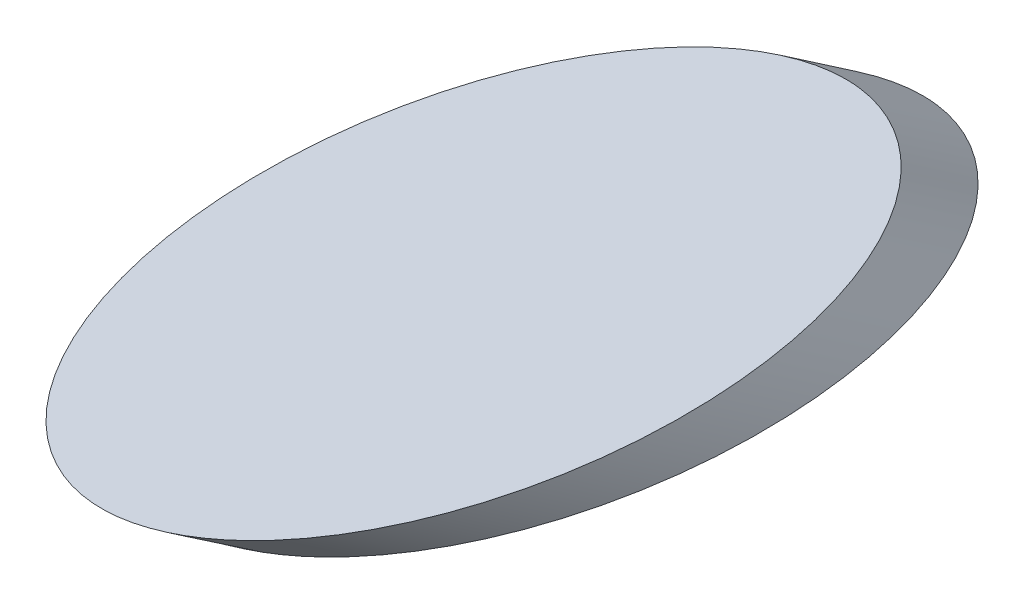
from build123d import *

# Parameters (mm, degrees)
SKETCH_1_RX = 14.115
SKETCH_1_RY = 8


with BuildPart() as part:
    # 扫描1: sweep along a path in 草图2
    with BuildLine(Plane(origin=(0, 0, 0), x_dir=(0, 0, -1), z_dir=(1, 0, 0))) as sweep_1_path:
        Line((-14.115, 0), (-11.19771593, -2))
    # 草图1 → 扫描1 (sweep)
    with BuildSketch(Plane(origin=(0, 0, 0), x_dir=(1, 0, 0), z_dir=(0, 1, 0))):
        with Locations(Location((0, 0), (0, 0, 90))):
            Ellipse(SKETCH_1_RX, SKETCH_1_RY)
    sweep(path=sweep_1_path.line)


solid = part.part
